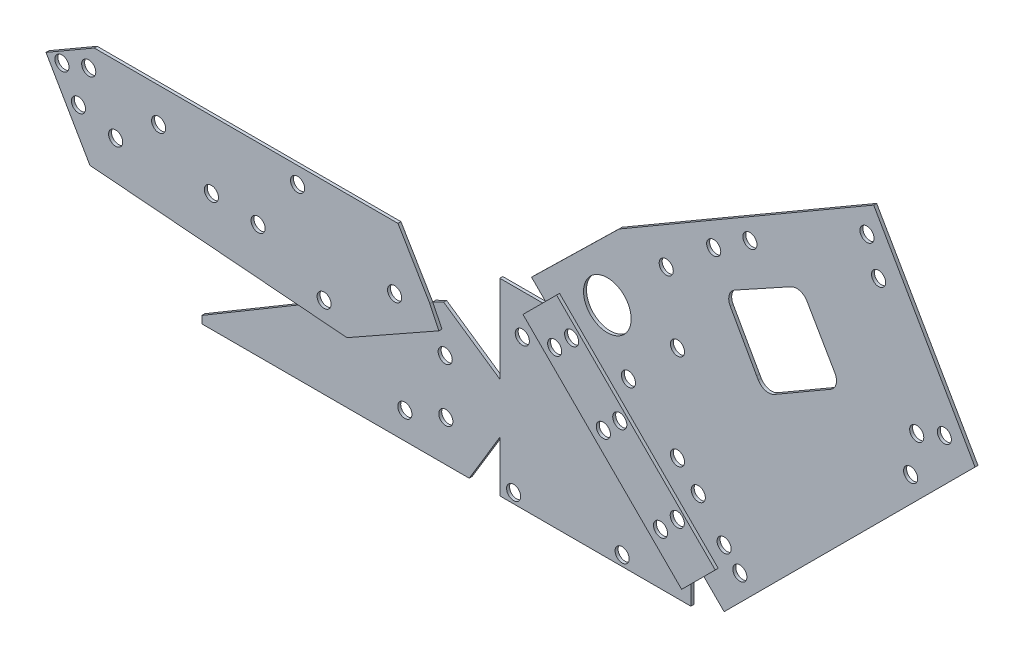
from build123d import *

# Parameters (mm, degrees)
ESBO_O1_R                  = 35.660641255
RESSALTO_EXTRUS_O1_DEPTH   = 15
ESBO_O1_3_R                = 35.660641255
ESBO_O1_3_R_2              = 120.313324473
RESSALTO_EXTRUS_O2_DEPTH   = 15
RESSALTO_EXTRUS_O2_2_DEPTH = 15
ESBO_O1_4_R                = 35.660641255
RESSALTO_EXTRUS_O3_DEPTH   = 15


with BuildPart() as part:
    # Esboço1 → Ressalto-extrusão1 (new body)
    with BuildSketch(Plane.XY):
        Polygon((4010.533399434, 2141.970944362), (4076.005101711, 2207.389266793), (4148.415471659, 2279.740599718), (3347.230793054, 3081.579026588), (3276.489171057, 3010.895081065), (3262.406085437, 2996.823477549), (3177.58137782, 2912.06792851), (3978.766056424, 2110.229501639), align=None)
        with Locations((3872.05125134, 2319.631811185)):
            Circle(ESBO_O1_R, mode=Mode.SUBTRACT)
        with Locations((3956.737617623, 2405.302902657)):
            Circle(ESBO_O1_R, mode=Mode.SUBTRACT)
        with Locations((3583.4303586, 2608.08398836)):
            Circle(ESBO_O1_R, mode=Mode.SUBTRACT)
        with Locations((3666.326183461, 2690.979813221)):
            Circle(ESBO_O1_R, mode=Mode.SUBTRACT)
        with Locations((3337.553750411, 2847.901723534)):
            Circle(ESBO_O1_R, mode=Mode.SUBTRACT)
        with Locations((3423.381012666, 2932.344675107)):
            Circle(ESBO_O1_R, mode=Mode.SUBTRACT)
    extrude(amount=RESSALTO_EXTRUS_O1_DEPTH)


with BuildPart() as body_2:
    # Esboço1<3> → Ressalto-extrusão2 (new body)
    with BuildSketch(Plane.XY):
        Polygon((5445.378190358, 3370.777629317), (4933.557676562, 4260.697795468), (4100.652822159, 3776.913538426), (3647.907243987, 3513.399888987), (3205.862854983, 3081.579026588), (3276.489171057, 3010.895081065), (3347.230793054, 3081.579026588), (4148.415471659, 2279.740599718), (4076.005101711, 2207.389266793), (4178.439197736, 2104.871586902), align=None)
        with Locations((4257.693014885, 2313.391749387)):
            Circle(ESBO_O1_3_R, mode=Mode.SUBTRACT)
        with Locations((4178.439197736, 2396.321714682)):
            Circle(ESBO_O1_3_R, mode=Mode.SUBTRACT)
        with Locations((4047.776540234, 2555.725462247)):
            Circle(ESBO_O1_3_R, mode=Mode.SUBTRACT)
        with Locations((3942.818302909, 2659.365198349)):
            Circle(ESBO_O1_3_R, mode=Mode.SUBTRACT)
        with Locations((3588.589452804, 3150.463941493)):
            Circle(ESBO_O1_3_R_2, mode=Mode.SUBTRACT)
        with Locations((3695.121557179, 2881.128662976)):
            Circle(ESBO_O1_3_R, mode=Mode.SUBTRACT)
        with Locations((3942.818302909, 3140.547759012)):
            Circle(ESBO_O1_3_R, mode=Mode.SUBTRACT)
        with Locations((3885.941003035, 3466.256374016)):
            Circle(ESBO_O1_3_R, mode=Mode.SUBTRACT)
        with Locations((4125.66098751, 3670.660916932)):
            Circle(ESBO_O1_3_R, mode=Mode.SUBTRACT)
        with Locations((5120.28393828, 3175.422188879)):
            Circle(ESBO_O1_3_R, mode=Mode.SUBTRACT)
        with Locations((5150.86333544, 3370.777629317)):
            Circle(ESBO_O1_3_R, mode=Mode.SUBTRACT)
        with BuildLine():
            Line((4350.874883247, 3204.127856726), (4342.39270444, 3218.764539058))
            Line((4342.39270444, 3218.764539058), (4209.160831455, 3456.626023185))
            ThreePointArc((4209.160831455, 3456.626023185), (4203.814969943, 3502.423342858), (4232.53986463, 3538.490684731))
            Line((4232.53986463, 3538.490684731), (4515.797951568, 3694.657978107))
            ThreePointArc((4515.797951568, 3694.657978107), (4560.819995822, 3699.92695684), (4596.679309134, 3672.198699512))
            Line((4596.679309134, 3672.198699512), (4737.941761109, 3428.438967258))
            ThreePointArc((4737.941761109, 3428.438967258), (4744.009632304, 3382.919607479), (4716.113217198, 3346.441926636))
            Line((4716.113217198, 3346.441926636), (4432.871923869, 3182.299312816))
            ThreePointArc((4432.871923869, 3182.299312816), (4387.352564091, 3176.231441621), (4350.874883247, 3204.127856726))
        make_face(mode=Mode.SUBTRACT)
        with Locations((5290.381834985, 3431.524640098)):
            Circle(ESBO_O1_3_R, mode=Mode.SUBTRACT)
        with Locations((4308.360072466, 3792.908098778)):
            Circle(ESBO_O1_3_R, mode=Mode.SUBTRACT)
        with Locations((4958.214201268, 3952.271832111)):
            Circle(ESBO_O1_3_R, mode=Mode.SUBTRACT)
        with Locations((4899.709282236, 4116.257791073)):
            Circle(ESBO_O1_3_R, mode=Mode.SUBTRACT)
    extrude(amount=-RESSALTO_EXTRUS_O2_DEPTH)


with BuildPart() as body_3:
    # Esboço1<3> → Ressalto-extrus_o2 2 (new body)
    with BuildSketch(Plane.XY):
        Polygon((4010.533399434, 2044.885956924), (4010.533399434, 2141.970944362), (3978.766056424, 2110.229501639), (3177.58137782, 2912.06792851), (3262.406085437, 2996.823477549), (3045.380804816, 2996.823477549), (3045.380804816, 2555.725462247), (2762.006486844, 2750.485306177), (2706.99299765, 2724.023121502), (2753.147730687, 2628.069860715), (2288.435772291, 2365.901546372), (2051.419844025, 2384.975589262), (1540.739088594, 2081.822141068), (1540.739088594, 2044.885956924), (2890.947777637, 2044.885956924), (3045.380804816, 2300.876731177), (3045.380804816, 2044.885956924), align=None)
        with Locations((3115.383590791, 2094.805485083)):
            Circle(ESBO_O1_3_R, mode=Mode.SUBTRACT)
        with Locations((3663.333708377, 2096.119514142)):
            Circle(ESBO_O1_3_R, mode=Mode.SUBTRACT)
        with Locations((3159.028297206, 2796.042579258)):
            Circle(ESBO_O1_3_R, mode=Mode.SUBTRACT)
        with Locations((2769.785644521, 2520.466473261)):
            Circle(ESBO_O1_3_R, mode=Mode.SUBTRACT)
        with Locations((2565.912714786, 2179.669370711)):
            Circle(ESBO_O1_3_R, mode=Mode.SUBTRACT)
        with Locations((2772.864379045, 2251.077202425)):
            Circle(ESBO_O1_3_R, mode=Mode.SUBTRACT)
    extrude(amount=-RESSALTO_EXTRUS_O2_2_DEPTH)


with BuildPart() as body_4:
    # Esboço1<4> → Ressalto-extrusão3 (new body)
    with BuildSketch(Plane.XY):
        Polygon((2753.147730687, 2628.069860715), (2706.99299765, 2724.023121502), (2546.319643023, 2994.687336631), (1012.624447891, 2994.687336631), (768.868518508, 2853.668623582), (990.631470443, 2470.343366368), (2051.419844025, 2384.975589262), (2288.435772291, 2365.901546372), align=None)
        with Locations((2173.19521695, 2472.085582863)):
            Circle(ESBO_O1_4_R, mode=Mode.SUBTRACT)
        with Locations((932.82609723, 2706.258497692)):
            Circle(ESBO_O1_4_R, mode=Mode.SUBTRACT)
        with Locations((1120.501661243, 2654.488109144)):
            Circle(ESBO_O1_4_R, mode=Mode.SUBTRACT)
        with Locations((849.423611828, 2847.179938543)):
            Circle(ESBO_O1_4_R, mode=Mode.SUBTRACT)
        with Locations((1337.695633644, 2822.584593531)):
            Circle(ESBO_O1_4_R, mode=Mode.SUBTRACT)
        with Locations((1604.089987399, 2654.1285998)):
            Circle(ESBO_O1_4_R, mode=Mode.SUBTRACT)
        with Locations((1839.832643921, 2636.666180798)):
            Circle(ESBO_O1_4_R, mode=Mode.SUBTRACT)
        with Locations((984.593157134, 2893.195102903)):
            Circle(ESBO_O1_4_R, mode=Mode.SUBTRACT)
        with Locations((2529.193138206, 2678.10991176)):
            Circle(ESBO_O1_4_R, mode=Mode.SUBTRACT)
        with Locations((2039.311514189, 2911.457125631)):
            Circle(ESBO_O1_4_R, mode=Mode.SUBTRACT)
    extrude(amount=RESSALTO_EXTRUS_O3_DEPTH)


solid = Compound([part.part, body_2.part, body_3.part, body_4.part])
